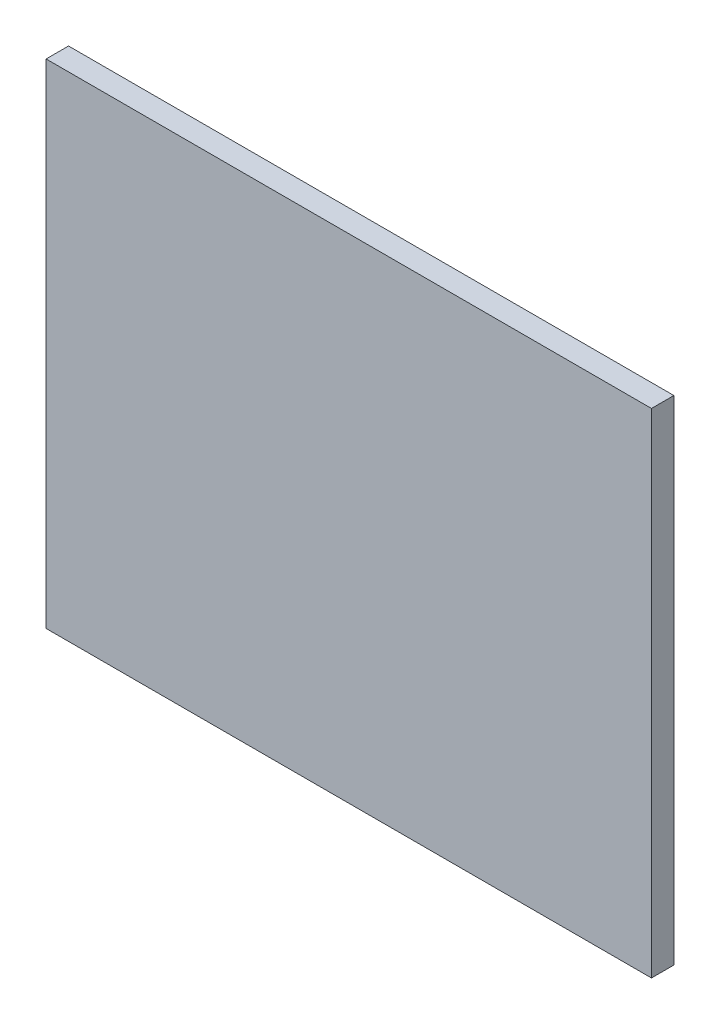
from build123d import *

# Parameters (mm, degrees)
ESBO_O1_W                = 27
ESBO_O1_H                = 22
RESSALTO_EXTRUS_O1_DEPTH = 1


with BuildPart() as part:
    # Esboço1 → Ressalto-extrusão1 (new body)
    with BuildSketch(Plane.XY):
        with Locations((-13.5, 11)):
            Rectangle(ESBO_O1_W, ESBO_O1_H)
    extrude(amount=RESSALTO_EXTRUS_O1_DEPTH)


solid = part.part
